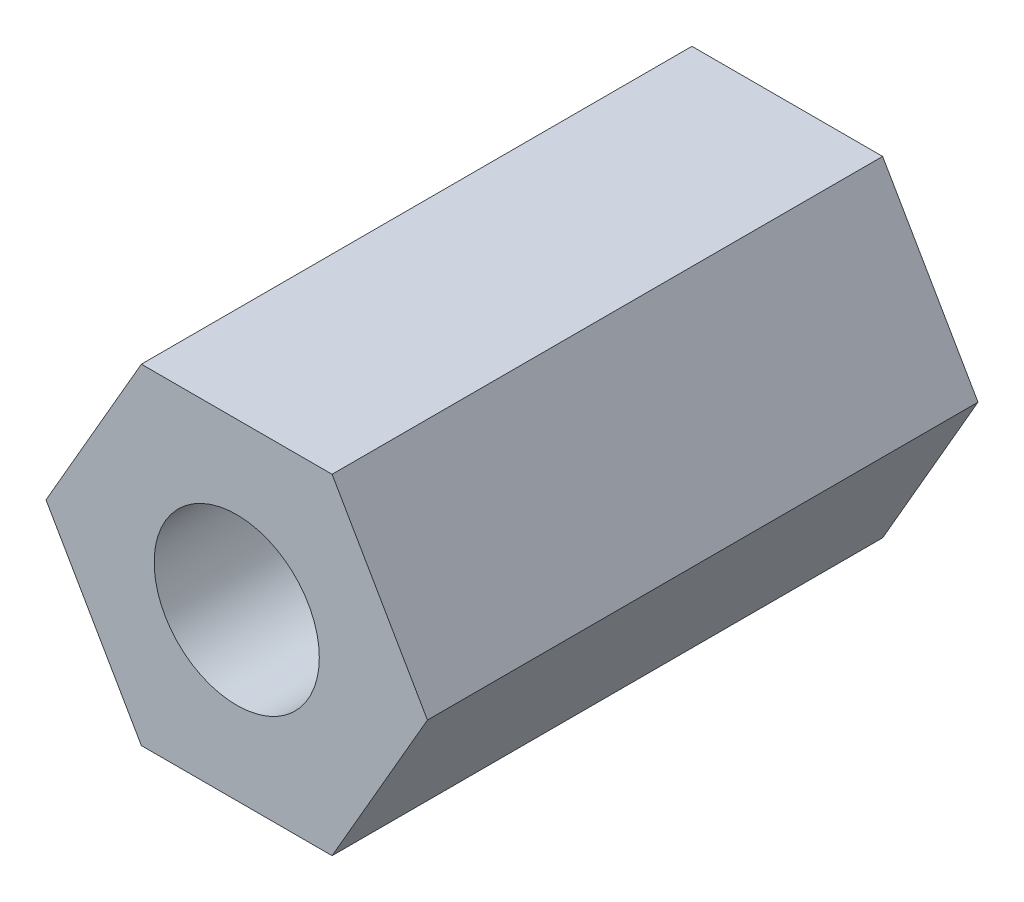
from build123d import *

# Parameters (mm, degrees)
ESBO_O1_R                = 1.5
RESSALTO_EXTRUS_O1_DEPTH = 10


with BuildPart() as part:
    # Esboço1 → Ressalto-extrusão1 (new body)
    with BuildSketch(Plane.XY):
        Polygon((3.464101615, 0), (1.732050808, 3), (-1.732050808, 3), (-3.464101615, 0), (-1.732050808, -3), (1.732050808, -3), align=None)
        Circle(ESBO_O1_R, mode=Mode.SUBTRACT)
    extrude(amount=RESSALTO_EXTRUS_O1_DEPTH)


solid = part.part
